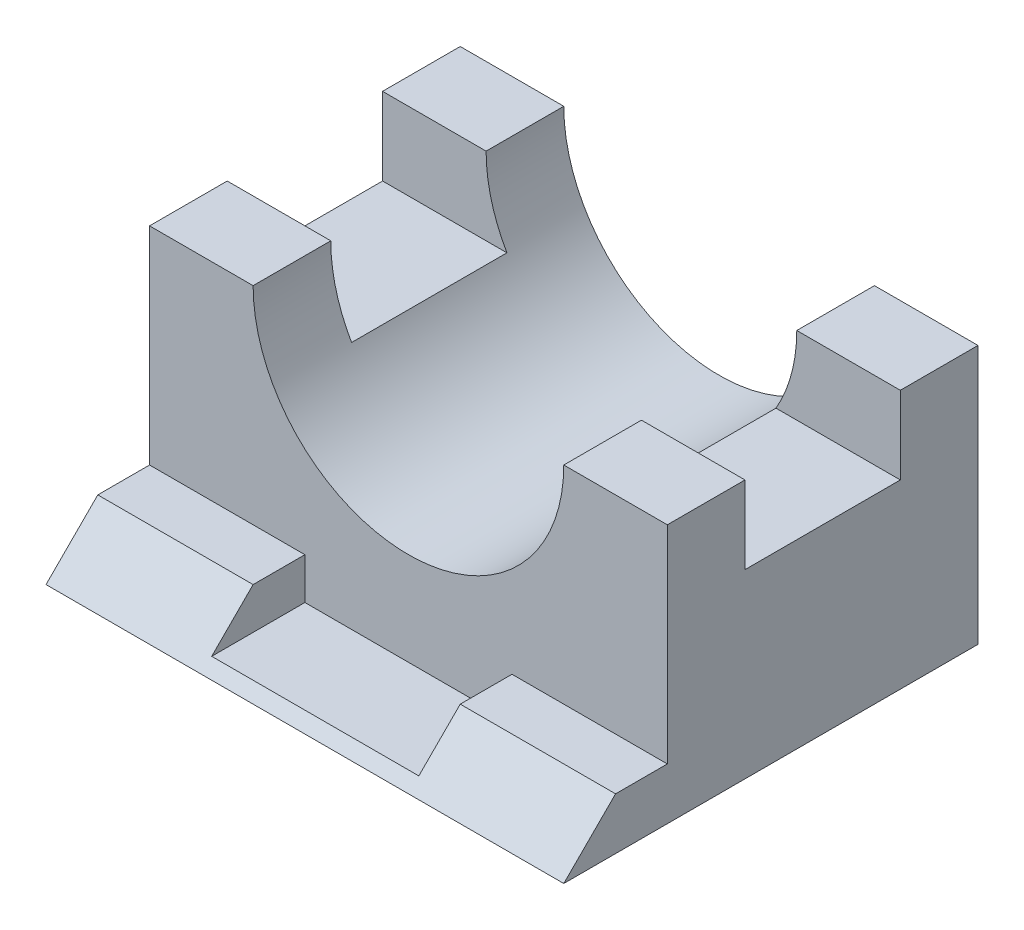
from build123d import *

# Parameters (mm, degrees)
BOSS_EXTRUDE1_DEPTH = 50
CUT_EXTRUDE1_DEPTH  = 100
SKETCH3_W           = 40
SKETCH3_H           = 8
CUT_EXTRUDE2_DEPTH  = 100


with BuildPart() as part:
    # Sketch1 → Boss-Extrude1 (new body, symmetric)
    with BuildSketch(Plane(origin=(0, 0, 0), x_dir=(0, 0, -1), z_dir=(1, 0, 0))):
        Polygon((-40, 0), (40, 0), (40, 50), (25, 50), (25, 35), (-5, 35), (-5, 50), (-20, 50), (-20, 10), (-30, 10), align=None)
    extrude(amount=BOSS_EXTRUDE1_DEPTH, both=True)

    # Sketch2 → Cut-Extrude1 (cut)
    with BuildSketch(Plane.XY.offset(20)):
        with BuildLine():
            Line((-30, 50), (30, 50))
            ThreePointArc((30, 50), (0, 20), (-30, 50))
        make_face()
    extrude(amount=-CUT_EXTRUDE1_DEPTH, mode=Mode.SUBTRACT)

    # Sketch3 → Cut-Extrude2 (cut)
    with BuildSketch(Plane.XY.offset(20)):
        with Locations((0, 6)):
            Rectangle(SKETCH3_W, SKETCH3_H)
    extrude(amount=CUT_EXTRUDE2_DEPTH, mode=Mode.SUBTRACT)


solid = part.part
